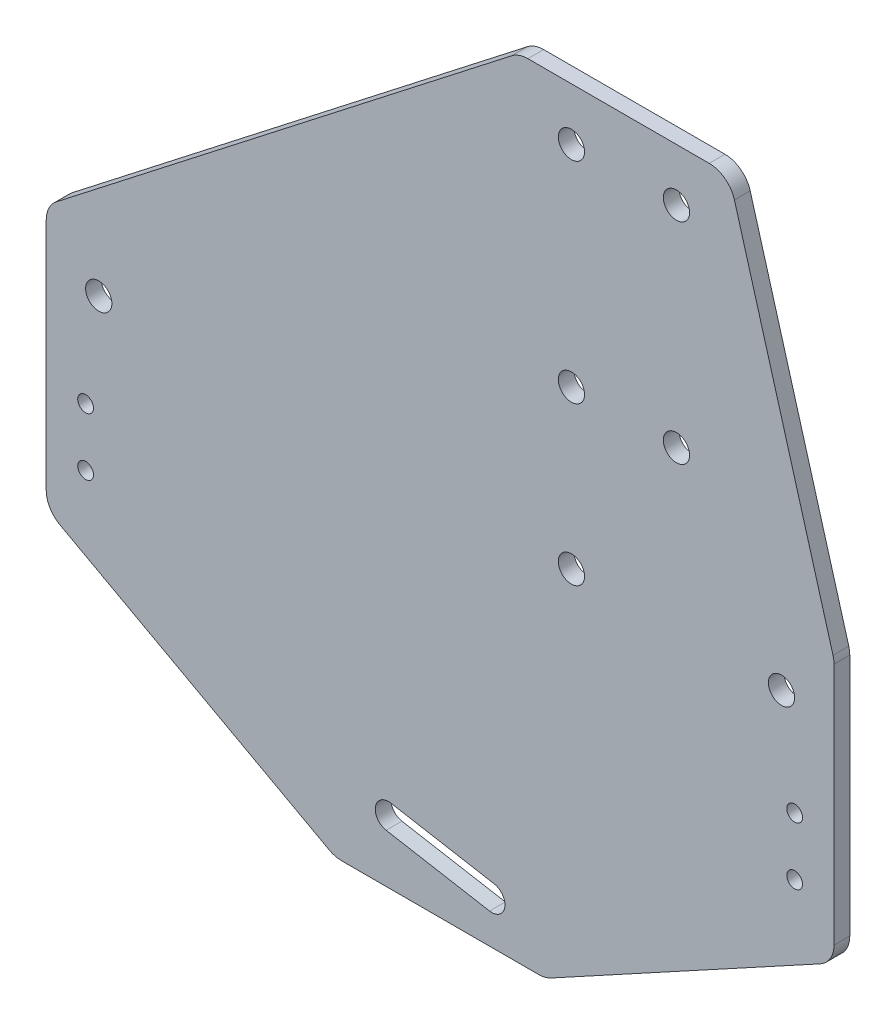
from build123d import *

# Parameters (mm, degrees)
BOSS_EXTRUDE1_DEPTH  = 3
SKETCH2_R            = 2.5
SKETCH2_R_2          = 1.5
CUT_EXTRUDE1_DEPTH   = 4
SKETCH3_R            = 2.5
CUT_EXTRUDE2_DEPTH   = 4
LPATTERN1_COUNT      = 2
LPATTERN1_PITCH      = 20
LPATTERN1_COUNT_DIR2 = 2
LPATTERN1_PITCH_DIR2 = 40
CUT_EXTRUDE3_DEPTH   = 4
FILLET1_R            = 5


with BuildPart() as part:
    # Sketch1 → Boss-Extrude1 (new body)
    with BuildSketch(Plane.XY):
        Polygon((-75, 0), (-75, 80), (15, 150), (55, 150), (75, 80), (75, 0), align=None)
    extrude(amount=BOSS_EXTRUDE1_DEPTH)

    # Sketch2 → Cut-Extrude1 (cut, through all)
    with BuildSketch(Plane.XY.offset(3)):
        with Locations((-65, 70)):
            Circle(SKETCH2_R)
        with Locations((65, 70)):
            Circle(SKETCH2_R)
        with Locations((67.5, 51)):
            Circle(SKETCH2_R_2)
        with Locations((25, 70)):
            Circle(SKETCH2_R)
        with Locations((67.5, 40)):
            Circle(SKETCH2_R_2)
        with Locations((-67.5, 51)):
            Circle(SKETCH2_R_2)
        with Locations((-67.5, 40)):
            Circle(SKETCH2_R_2)
        with BuildLine():
            Line((-9.413957086, 14.198501159), (10.282197974, 10.725537606))
            ThreePointArc((10.282197974, 10.725537606), (12.310096913, 7.829397779), (9.413957086, 5.801498841))
            Line((9.413957086, 5.801498841), (-10.282197974, 9.274462394))
            ThreePointArc((-10.282197974, 9.274462394), (-12.310096913, 12.170602221), (-9.413957086, 14.198501159))
        make_face()
    extrude(amount=-CUT_EXTRUDE1_DEPTH, mode=Mode.SUBTRACT)

    # Sketch3 → Cut-Extrude2 (cut, through all)
    with BuildSketch(Plane.XY.offset(3)):
        with Locations((45, 140)):
            Circle(SKETCH3_R)
    cut_extrude2 = extrude(amount=-CUT_EXTRUDE2_DEPTH, mode=Mode.SUBTRACT)

    # LPattern1: Cut-Extrude2 2 × 2
    with Locations(*[(-i * LPATTERN1_PITCH, -j * LPATTERN1_PITCH_DIR2, 0) for i in range(LPATTERN1_COUNT) for j in range(LPATTERN1_COUNT_DIR2) if (i, j) != (0, 0)]):
        add(cut_extrude2, mode=Mode.SUBTRACT)

    # Sketch4 → Cut-Extrude3 (cut, through all)
    with BuildSketch(Plane.XY.offset(3)):
        Polygon((-75, 30), (-20, 0), (-75, 0), align=None)
        Polygon((20, 0), (75, 30), (75, 0), align=None)
    extrude(amount=-CUT_EXTRUDE3_DEPTH, mode=Mode.SUBTRACT)

    # Fillet1
    fillet1_edges = [part.edges().sort_by_distance(p)[0] for p in [
        (55, 150, 1.5),
        (75, 80, 1.5),
        (-75, 80, 1.5),
        (15, 150, 1.5),
        (-75, 30, 1.5),
        (-20, 0, 1.5),
        (20, 0, 1.5),
        (75, 30, 1.5),
    ]]
    fillet(fillet1_edges, radius=FILLET1_R)


solid = part.part
